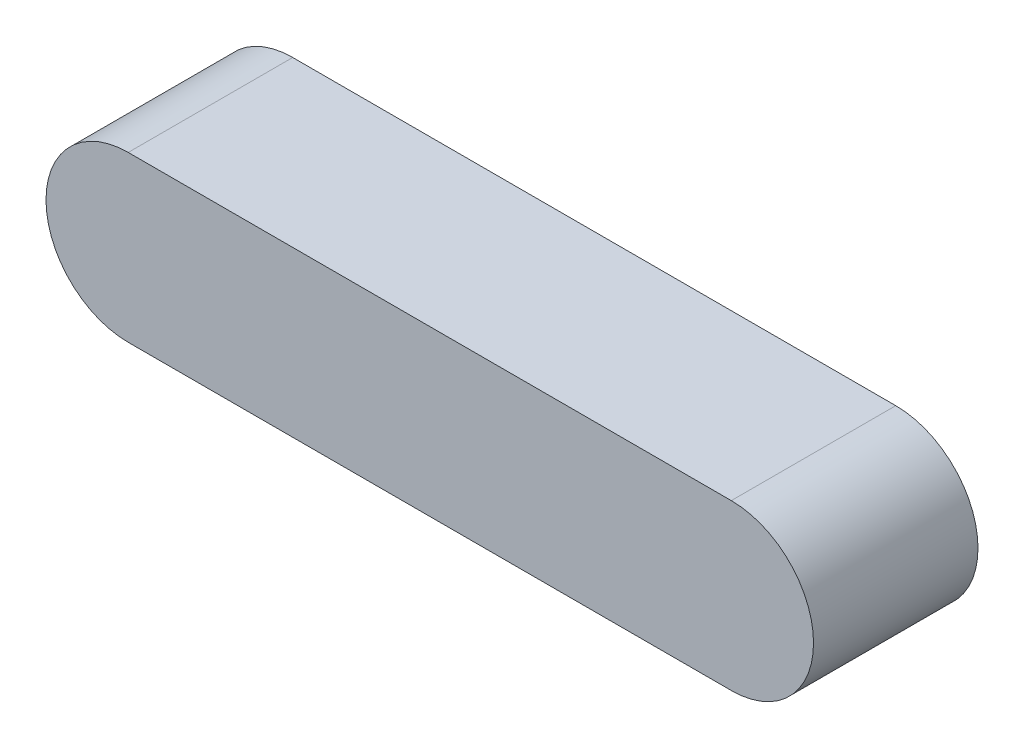
from build123d import *

# Parameters (mm, degrees)
BOSS_EXTRUDE1_DEPTH = 3


with BuildPart() as part:
    # Sketch1 → Boss-Extrude1 (new body)
    with BuildSketch(Plane.XY):
        with BuildLine():
            Line((0, 1.5), (11, 1.5))
            ThreePointArc((11, 1.5), (12.5, 0), (11, -1.5))
            Line((11, -1.5), (0, -1.5))
            ThreePointArc((0, -1.5), (-1.5, 0), (0, 1.5))
        make_face()
    extrude(amount=BOSS_EXTRUDE1_DEPTH)


solid = part.part
